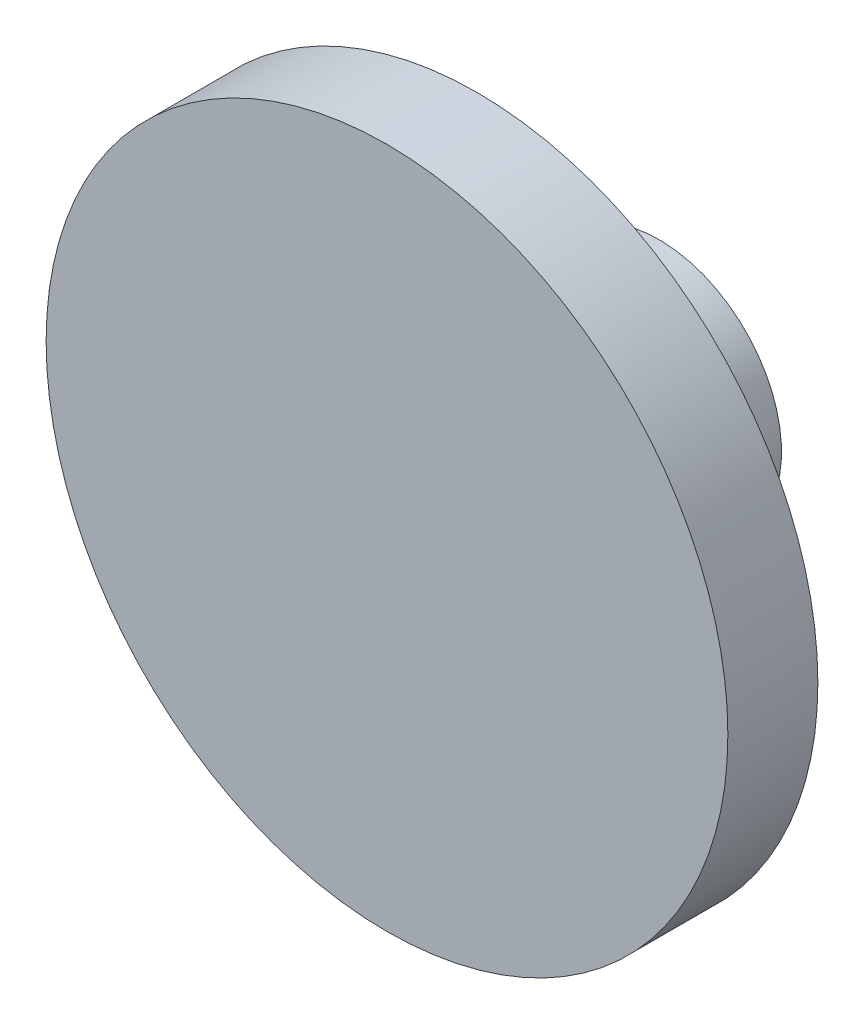
from build123d import *


with BuildPart() as part:
    # Sketch2 → Revolve1 (revolve)
    with BuildSketch(Plane(origin=(0, 0, 0), x_dir=(0, 0, -1), z_dir=(1, 0, 0))):
        Polygon((-35.5, -5.251776718), (-35.5, 39.248223282), (-23.75, 39.248223282), (-23.75, 10.748223282), (0, 10.748223282), (0, -5.251776718), align=None)
    revolve(axis=Axis((0, -5.251776718, 0), (0, 0, 1)))


solid = part.part
